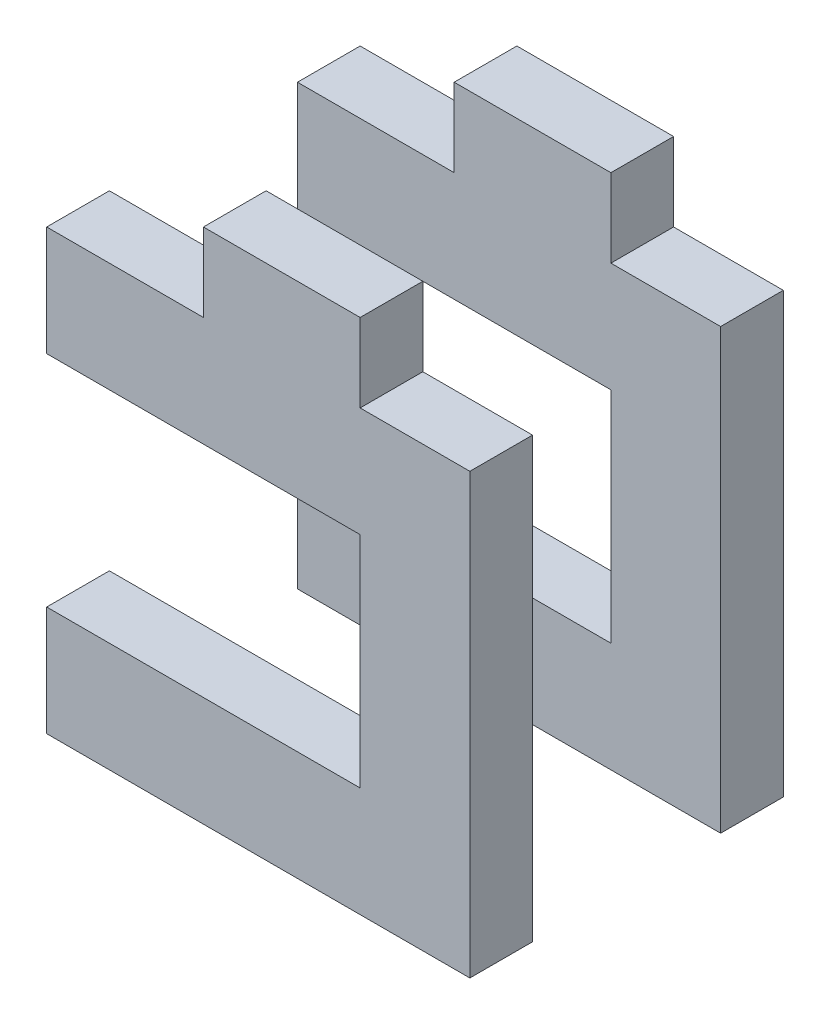
from build123d import *

# Parameters (mm, degrees)
EXTRUDE_1_DEPTH        = 2
PATTERN_LINEAR_1_COUNT = 2
PATTERN_LINEAR_1_PITCH = 8


with BuildPart() as part:
    # 草图8 → 凸台-拉伸1 (new body)
    with BuildSketch(Plane.XY):
        Polygon((7713.406970683, 2376.570087092), (7713.406970683, 2369.570087092), (7703.406970683, 2369.570087092), (7703.406970683, 2367.570087092), (7703.406970683, 2366.070087092), (7716.906970683, 2366.070087092), (7716.906970683, 2367.570087092), (7716.906970683, 2378.570087092), (7716.906970683, 2380.070087092), (7713.406970683, 2380.070087092), (7713.406970683, 2382.570087092), (7708.406970683, 2382.570087092), (7708.406970683, 2380.070087092), (7703.406970683, 2380.070087092), (7703.406970683, 2378.570087092), (7703.406970683, 2376.570087092), align=None)
    extrude(amount=EXTRUDE_1_DEPTH)


with BuildPart() as pattern_linear_1_1:
    # 阵列(线性)1: pattern copy
    add(part.part.moved(Location(Vector(0, 0, 1) * (1 * PATTERN_LINEAR_1_PITCH))))


solid = Compound([part.part, pattern_linear_1_1.part])
